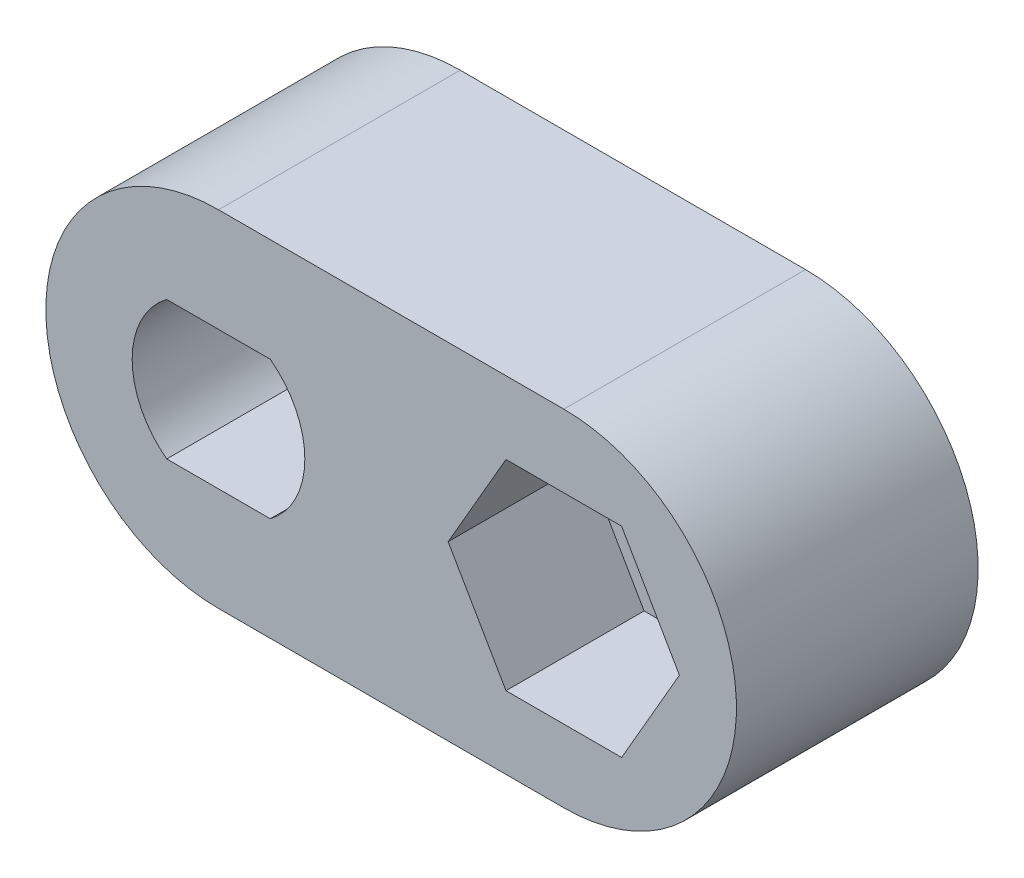
from build123d import *

# Parameters (mm, degrees)
EXTRUDE_1_DEPTH              = 7
CUT_EXTRUDE_1_DEPTH          = 4
HOLE_WIZARD_M3_1_D           = 3.4
HOLE_WIZARD_M3_1_DEPTH       = 7.5
HOLE_WIZARD_M3_1_CSINK_D     = 6.72
HOLE_WIZARD_M3_1_CSINK_ANGLE = 90
HOLE_WIZARD_M3_1_TIP         = 1.021463052
HOLE_WIZARD_1_D              = 4.15
CUT_EXTRUDE_2_DEPTH          = 4


with BuildPart() as part:
    # 草图1 → 凸台-拉伸1 (new body)
    with BuildSketch(Plane.XY):
        with BuildLine():
            Line((0, 5), (10, 5))
            ThreePointArc((10, 5), (15, 0), (10, -5))
            Line((10, -5), (0, -5))
            ThreePointArc((0, -5), (-5, 0), (0, 5))
        make_face()
    extrude(amount=EXTRUDE_1_DEPTH)

    # 草图2 → 切除-拉伸1 (cut)
    with BuildSketch(Plane.XY.offset(7)):
        with BuildLine():
            Line((1.5, 2), (-1.5, 2))
            ThreePointArc((-1.5, 2), (-2.5, 0), (-1.5, -2))
            Line((-1.5, -2), (1.5, -2))
            ThreePointArc((1.5, -2), (2.236067977, -1.118033989), (2.5, 0))
            ThreePointArc((2.5, 0), (2.236067977, 1.118033989), (1.5, 2))
        make_face()
    extrude(amount=-CUT_EXTRUDE_1_DEPTH, mode=Mode.SUBTRACT)

    # M3 六角凹锥坑螺钉的锥形沉头孔1
    with Locations(Plane(origin=(0, 0, 0), x_dir=(-1, 0, 0), z_dir=(0, 0, -1))):
        with Locations((0, 0)):
            CounterSinkHole(HOLE_WIZARD_M3_1_D / 2, HOLE_WIZARD_M3_1_CSINK_D / 2, depth=HOLE_WIZARD_M3_1_DEPTH, counter_sink_angle=HOLE_WIZARD_M3_1_CSINK_ANGLE)
            with Locations((0, 0, -(HOLE_WIZARD_M3_1_DEPTH + HOLE_WIZARD_M3_1_TIP / 2))):  # 118° drill point
                Cone(0, HOLE_WIZARD_M3_1_D / 2, HOLE_WIZARD_M3_1_TIP, mode=Mode.SUBTRACT)

    # 孔1 (through all)
    with Locations(Plane(origin=(0, 0, 0), x_dir=(-1, 0, 0), z_dir=(0, 0, -1))):
        with Locations((-10, 0)):
            Hole(HOLE_WIZARD_1_D / 2)

    # 草图7 → 切除-拉伸2 (cut)
    with BuildSketch(Plane.XY.offset(7)):
        Polygon((8.325684219, -2.9), (11.674315781, -2.9), (13.348631561, 0), (11.674315781, 2.9), (8.325684219, 2.9), (6.651368439, 0), align=None)
    extrude(amount=-CUT_EXTRUDE_2_DEPTH, mode=Mode.SUBTRACT)


solid = part.part
